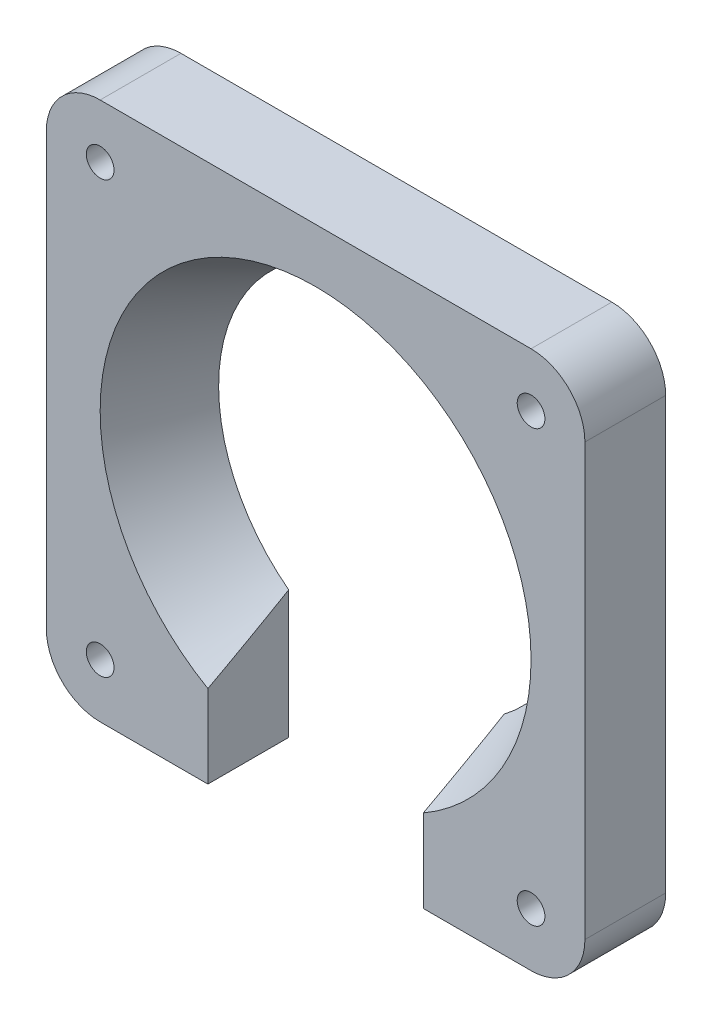
from build123d import *

# Parameters (mm, degrees)
SKETCH1_W           = 63.5
SKETCH1_H           = 63.5
BOSS_EXTRUDE1_DEPTH = 9.525
SKETCH2_R           = 25.4
CUT_EXTRUDE1_DEPTH  = 12.7
CUT_EXTRUDE1_DRAFT  = -25
SKETCH3_W           = 25.4
SKETCH3_H           = 28.786668085
CUT_EXTRUDE2_DEPTH  = 9.525
SKETCH4_R           = 1.63195
CUT_EXTRUDE3_DEPTH  = 9.525
FILLET1_R           = 6.35
FILLET2_R           = 6.35


with BuildPart() as part:
    # Sketch1 → Boss-Extrude1 (new body)
    with BuildSketch(Plane.XY):
        with Locations((4.40013587, -6.298233696)):
            Rectangle(SKETCH1_W, SKETCH1_H)
    extrude(amount=BOSS_EXTRUDE1_DEPTH)


with BuildPart() as cut_extrude1_tool:
    # Sketch2 → Cut-Extrude1 (with draft: the straight prism first)
    with BuildSketch(Plane.XY.offset(9.525)):
        with Locations((4.40013587, -6.298233696)):
            Circle(SKETCH2_R)
    extrude(amount=-CUT_EXTRUDE1_DEPTH)
    # Cut-Extrude1: the draft: its side faces are tilted about the plane it starts from
    cut_extrude1_sides = [cut_extrude1_tool.faces().sort_by_distance(p)[0] for p in [
        (-20.99986413, -6.298233696, 3.175),
    ]]
    draft(cut_extrude1_sides, Plane.XY.offset(9.525), CUT_EXTRUDE1_DRAFT)


with BuildPart() as part_1:
    add(part.part)

    # Cut-Extrude1: cut by cut_extrude1_tool
    add(cut_extrude1_tool.part, mode=Mode.SUBTRACT)

    # Sketch3 → Cut-Extrude2 (cut)
    with BuildSketch(Plane.XY.offset(9.525)):
        with Locations((4.40013587, -23.654899654)):
            Rectangle(SKETCH3_W, SKETCH3_H)
    extrude(amount=-CUT_EXTRUDE2_DEPTH, mode=Mode.SUBTRACT)

    # Sketch4 → Cut-Extrude3 (cut)
    with BuildSketch(Plane.XY.offset(9.525)):
        with Locations((-20.99986413, 19.101766304)):
            Circle(SKETCH4_R)
        with Locations((29.80013587, 19.101766304)):
            Circle(SKETCH4_R)
        with Locations((29.80013587, -31.698233696)):
            Circle(SKETCH4_R)
        with Locations((-20.99986413, -31.698233696)):
            Circle(SKETCH4_R)
    extrude(amount=-CUT_EXTRUDE3_DEPTH, mode=Mode.SUBTRACT)

    # Fillet1
    fillet1_edges = [part_1.edges().sort_by_distance(p)[0] for p in [
        (-27.34986413, 25.451766304, 4.7625),
        (36.15013587, 25.451766304, 4.7625),
        (-27.34986413, -38.048233696, 4.7625),
    ]]
    fillet(fillet1_edges, radius=FILLET1_R)

    # Fillet2
    fillet2_edges = [part_1.edges().sort_by_distance(p)[0] for p in [
        (36.15013587, -38.048233696, 4.7625),
    ]]
    fillet(fillet2_edges, radius=FILLET2_R)


solid = part_1.part
